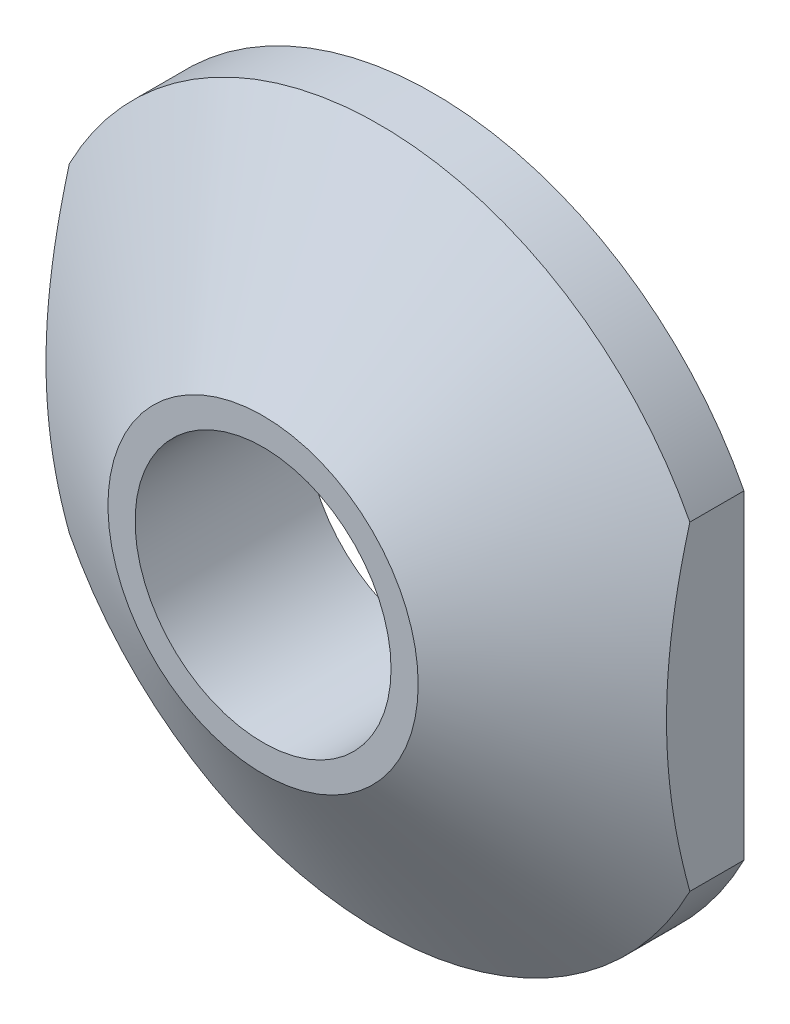
from build123d import *

# Parameters (mm, degrees)
SKETCH3_W          = 2.43419071
SKETCH3_H          = 7.16478775
CUT_EXTRUDE1_DEPTH = 3.2


with BuildPart() as part:
    # Sketch2 → Revolve1 (revolve)
    with BuildSketch(Plane(origin=(0, 0, 0), x_dir=(1, 0, 0), z_dir=(0, 1, 0))):
        Polygon((2, 0), (4.5, 1.502151548), (4.5, 2.2), (1.65, 2.2), (1.65, 0), align=None)
    revolve(axis=Axis((0, 0, 0), (0, 0, -1)))

    # Sketch3 → Cut-Extrude1 (cut, through all)
    with BuildSketch(Plane(origin=(0, 0, -2.2), x_dir=(-1, 0, 0), z_dir=(0, 0, -1))):
        with Locations((-5.217095355, -0.122475004)):
            Rectangle(SKETCH3_W, SKETCH3_H)
    cut_extrude1 = extrude(amount=-CUT_EXTRUDE1_DEPTH, mode=Mode.SUBTRACT)

    # Mirror1: Cut-Extrude1 across plane
    add(cut_extrude1.mirror(Plane(origin=(0, 0, 0), x_dir=(0, 0, 1), z_dir=(1, 0, 0))), mode=Mode.SUBTRACT)


solid = part.part
